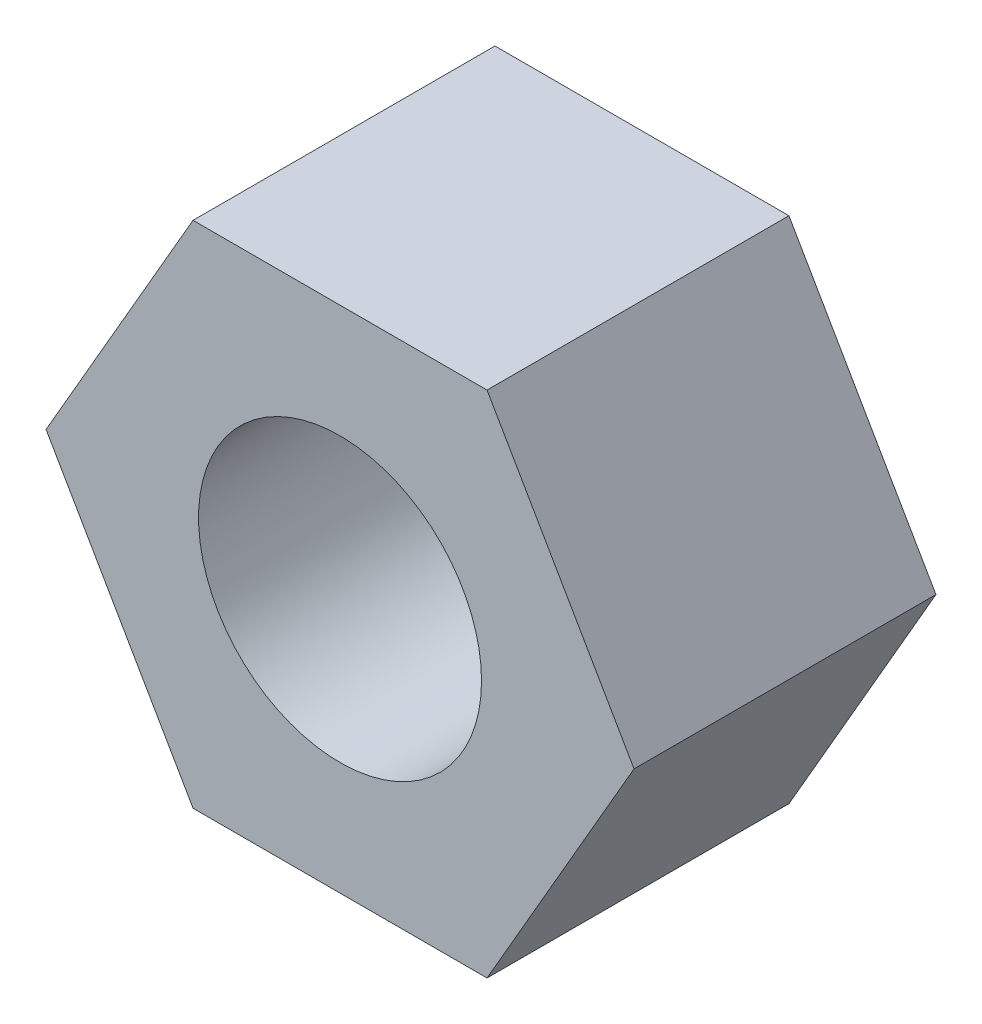
from build123d import *

# Parameters (mm, degrees)
SKETCH1_R           = 3.9878
BOSS_EXTRUDE1_DEPTH = 8.509


with BuildPart() as part:
    # Sketch1 → Boss-Extrude1 (new body)
    with BuildSketch(Plane.XY):
        Polygon((8.285553713, 0), (4.142776857, 7.1755), (-4.142776857, 7.1755), (-8.285553713, 0), (-4.142776857, -7.1755), (4.142776857, -7.1755), align=None)
        Circle(SKETCH1_R, mode=Mode.SUBTRACT)
    extrude(amount=BOSS_EXTRUDE1_DEPTH)


solid = part.part
